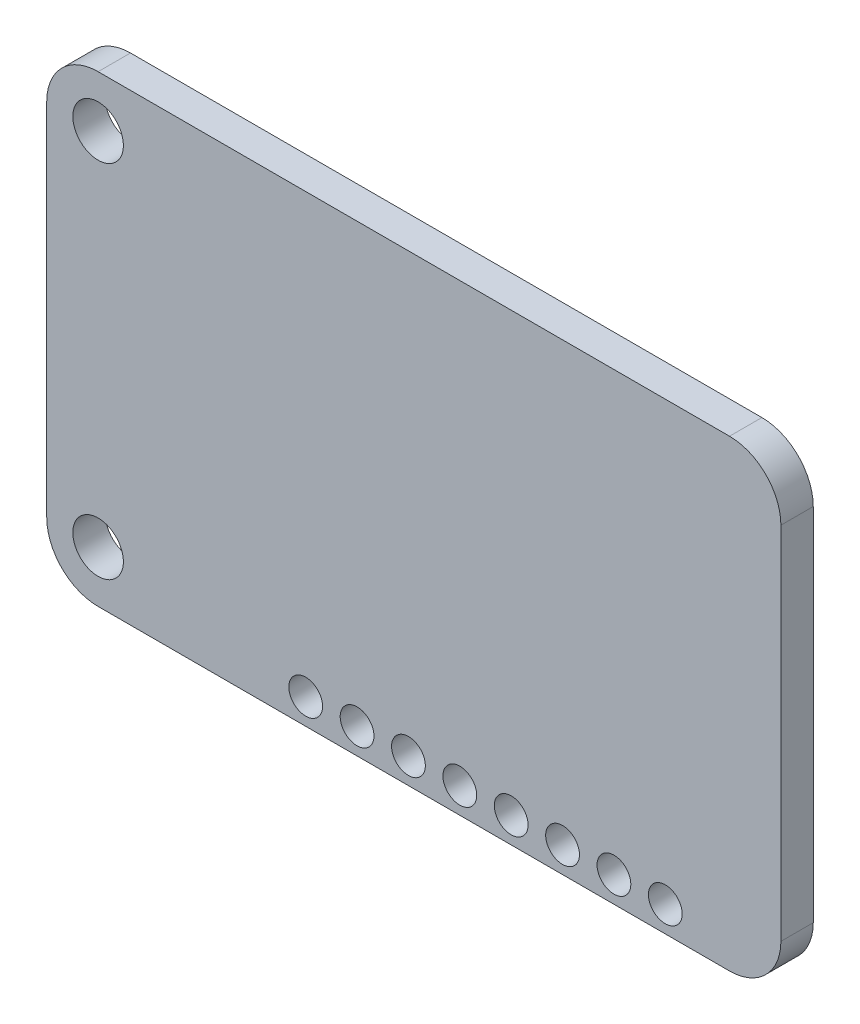
from build123d import *

# Parameters (mm, degrees)
SKETCH1_R           = 1.25
BOSS_EXTRUDE1_DEPTH = 1.6
SKETCH2_R           = 0.835
CUT_EXTRUDE1_DEPTH  = 10


with BuildPart() as part:
    # Sketch1 → Boss-Extrude1 (new body)
    with BuildSketch(Plane.XY):
        with BuildLine():
            Line((15.61, -11.45), (-15.61, -11.45))
            ThreePointArc((-15.61, -11.45), (-17.406051224, -10.706051224), (-18.15, -8.91))
            Line((-18.15, -8.91), (-18.15, 8.91))
            ThreePointArc((-18.15, 8.91), (-17.406051224, 10.706051224), (-15.61, 11.45))
            Line((-15.61, 11.45), (15.61, 11.45))
            ThreePointArc((15.61, 11.45), (17.406051224, 10.706051224), (18.15, 8.91))
            Line((18.15, 8.91), (18.15, -8.91))
            ThreePointArc((18.15, -8.91), (17.406051224, -10.706051224), (15.61, -11.45))
        make_face()
        with Locations((-15.61, 8.91)):
            Circle(SKETCH1_R, mode=Mode.SUBTRACT)
        with Locations((-15.61, -8.91)):
            Circle(SKETCH1_R, mode=Mode.SUBTRACT)
    extrude(amount=BOSS_EXTRUDE1_DEPTH)

    # Sketch2 → Cut-Extrude1 (cut)
    with BuildSketch(Plane.XY.offset(1.6)):
        with Locations((12.4347, -10.18)):
            Circle(SKETCH2_R)
        with Locations((9.8947, -10.18)):
            Circle(SKETCH2_R)
        with Locations((7.3547, -10.18)):
            Circle(SKETCH2_R)
        with Locations((4.8147, -10.18)):
            Circle(SKETCH2_R)
        with Locations((2.2747, -10.18)):
            Circle(SKETCH2_R)
        with Locations((-0.2653, -10.18)):
            Circle(SKETCH2_R)
        with Locations((-2.8053, -10.18)):
            Circle(SKETCH2_R)
        with Locations((-5.3453, -10.18)):
            Circle(SKETCH2_R)
    extrude(amount=-CUT_EXTRUDE1_DEPTH, mode=Mode.SUBTRACT)


solid = part.part
